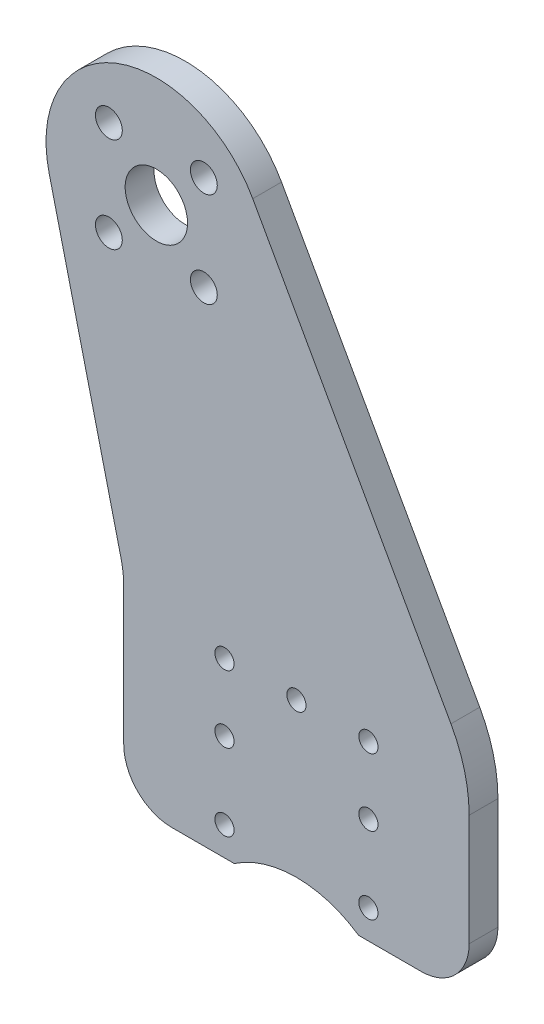
from build123d import *

# Parameters (mm, degrees)
SKETCH_1_R      = 3.25
SKETCH_1_R_2    = 1.4
SKETCH_1_R_3    = 1
EXTRUDE_1_DEPTH = 3


with BuildPart() as part:
    # Эскиз1 → Бобышка-Вытянуть1 (new body)
    with BuildSketch(Plane.XY):
        with BuildLine():
            Line((1.6, -55.377499952), (8.119259302, -55.377499952))
            ThreePointArc((8.119259302, -55.377499952), (14.6, -53.377499952), (21.080740698, -55.377499952))
            Line((21.080740698, -55.377499952), (27.6, -55.377499952))
            ThreePointArc((27.6, -55.377499952), (31.135533906, -53.913033858), (32.6, -50.377499952))
            Line((32.6, -50.377499952), (32.6, -38.774674064))
            ThreePointArc((32.6, -38.774674064), (32.11800347, -35.002728245), (30.702989966, -31.473191066))
            Line((30.702989966, -31.473191066), (10.04562564, 5.597803631))
            ThreePointArc((10.04562564, 5.597803631), (-4.188430146, 10.710137857), (-11.17802813, -2.702163414))
            Line((-11.17802813, -2.702163414), (-3.679975539, -33.719326307))
            ThreePointArc((-3.679975539, -33.719326307), (-3.470240572, -34.885869352), (-3.4, -36.069033624))
            Line((-3.4, -36.069033624), (-3.4, -50.377499952))
            ThreePointArc((-3.4, -50.377499952), (-1.935533906, -53.913033858), (1.6, -55.377499952))
        make_face()
        Circle(SKETCH_1_R, mode=Mode.SUBTRACT)
        with Locations((-4.949747468, 4.949747468)):
            Circle(SKETCH_1_R_2, mode=Mode.SUBTRACT)
        with Locations((4.949747468, 4.949747468)):
            Circle(SKETCH_1_R_2, mode=Mode.SUBTRACT)
        with Locations((4.949747468, -4.949747468)):
            Circle(SKETCH_1_R_2, mode=Mode.SUBTRACT)
        with Locations((-4.949747468, -4.949747468)):
            Circle(SKETCH_1_R_2, mode=Mode.SUBTRACT)
        with Locations((7.1, -37.377499952)):
            Circle(SKETCH_1_R_3, mode=Mode.SUBTRACT)
        with Locations((22.1, -37.377499952)):
            Circle(SKETCH_1_R_3, mode=Mode.SUBTRACT)
        with Locations((7.1, -52.377499952)):
            Circle(SKETCH_1_R_3, mode=Mode.SUBTRACT)
        with Locations((22.1, -52.377499952)):
            Circle(SKETCH_1_R_3, mode=Mode.SUBTRACT)
        with Locations((14.6, -37.377499952)):
            Circle(SKETCH_1_R_3, mode=Mode.SUBTRACT)
        with Locations((22.1, -44.377499952)):
            Circle(SKETCH_1_R_3, mode=Mode.SUBTRACT)
        with Locations((7.1, -44.377499952)):
            Circle(SKETCH_1_R_3, mode=Mode.SUBTRACT)
    extrude(amount=-EXTRUDE_1_DEPTH)


solid = part.part
